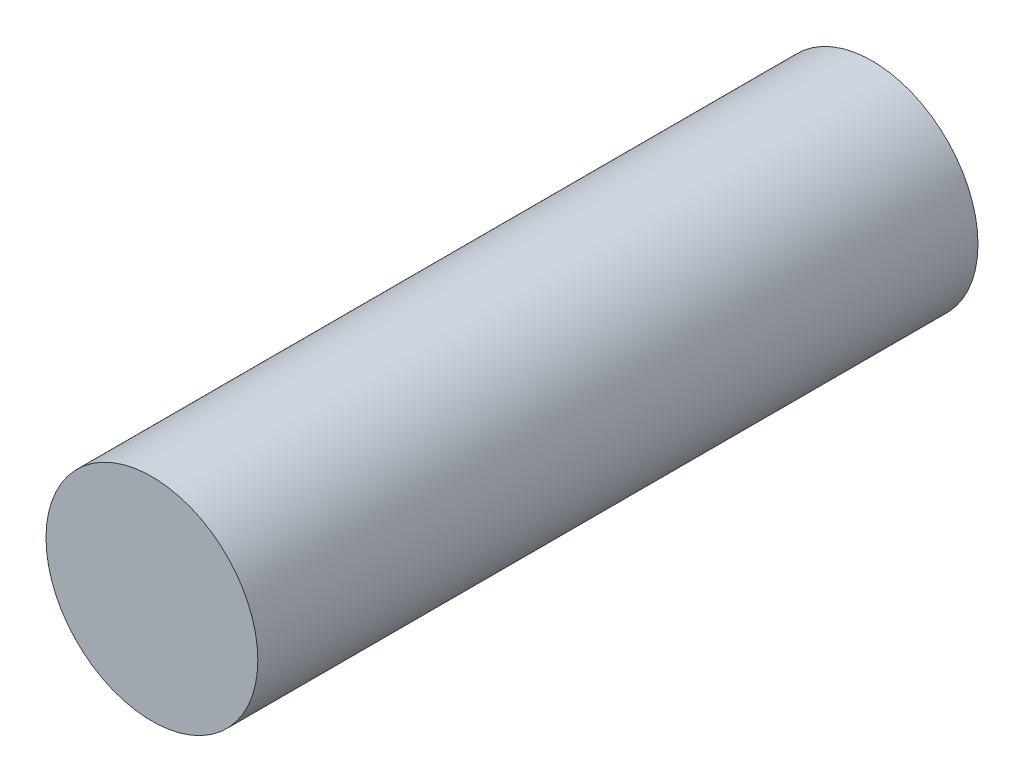
from build123d import *

# Parameters (mm, degrees)
SKETCH1_R           = 25
BOSS_EXTRUDE1_DEPTH = 170


with BuildPart() as part:
    # Sketch1 → Boss-Extrude1 (new body)
    with BuildSketch(Plane.XY):
        Circle(SKETCH1_R)
    extrude(amount=BOSS_EXTRUDE1_DEPTH)


solid = part.part
